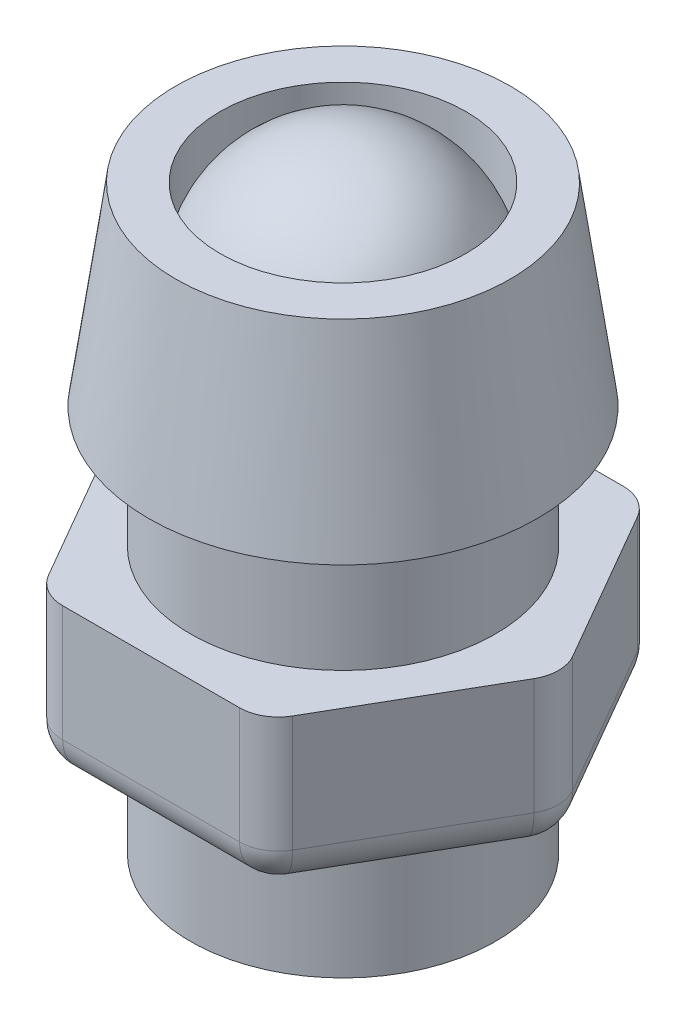
from build123d import *

# Parameters (mm, degrees)
SKETCH2_R           = 3.175
CUT_EXTRUDE1_DEPTH  = 16
BOSS_EXTRUDE1_DEPTH = 4
FILLET1_R           = 1
FILLET2_R           = 1


with BuildPart() as part:
    # Sketch1 → Revolve1 (revolve)
    with BuildSketch(Plane.XY):
        Polygon((0, 0), (0, 15), (4.318, 15), (5.020704174, 10), (3.937, 10), (3.937, 0), align=None)
    revolve(axis=Axis((0, 0, 0), (0, 1, 0)))

    # Sketch2 → Cut-Extrude1 (cut, through all)
    with BuildSketch(Plane(origin=(0, 15, 0), x_dir=(1, 0, 0), z_dir=(0, 1, 0))):
        Circle(SKETCH2_R)
    extrude(amount=-CUT_EXTRUDE1_DEPTH, mode=Mode.SUBTRACT)

    # Sketch4 → Boss-Extrude1 (add)
    with BuildSketch(Plane(origin=(0, 6.875, 0), x_dir=(-1, 0, 0), z_dir=(0, -1, 0))):
        Polygon((5.719231767, 0), (2.859615883, 4.953), (-2.859615883, 4.953), (-5.719231767, 0), (-2.859615883, -4.953), (2.859615883, -4.953), align=None)
    extrude(amount=BOSS_EXTRUDE1_DEPTH)

    # Fillet1
    fillet1_edges = [part.edges().sort_by_distance(p)[0] for p in [
        (-2.859615883, 4.875, 4.953),
        (-5.719231767, 4.875, 0),
        (-2.859615883, 4.875, -4.953),
        (2.859615883, 4.875, -4.953),
        (5.719231767, 4.875, 0),
        (2.859615883, 4.875, 4.953),
    ]]
    fillet(fillet1_edges, radius=FILLET1_R)

    # Fillet2
    fillet2_edges = [part.edges().sort_by_distance(p)[0] for p in [
        (4.289423825, 2.875, 2.4765),
        (4.289423825, 2.875, -2.4765),
        (-4.289423825, 2.875, 2.4765),
        (-4.289423825, 2.875, -2.4765),
        (0, 2.875, -4.953),
        (0, 2.875, 4.953),
        (2.782265614, 2.875, 4.819025404),
        (-2.782265614, 2.875, 4.819025404),
        (-5.564531228, 2.875, 0),
        (-2.782265614, 2.875, -4.819025404),
        (2.782265614, 2.875, -4.819025404),
        (5.564531228, 2.875, 0),
    ]]
    fillet(fillet2_edges, radius=FILLET2_R)


with BuildPart() as body_2:
    # Sketch3 → Revolve2 (revolve)
    with BuildSketch(Plane.XY):
        with BuildLine():
            Line((0, 16), (0, 13.599652711))
            Line((0, 13.599652711), (3.175, 13.599652711))
            ThreePointArc((3.175, 13.599652711), (1.990118848, 15.332380476), (0, 16))
        make_face()
    revolve(axis=Axis((0, 0, 0), (0, 1, 0)))


solid = Compound([part.part, body_2.part])
